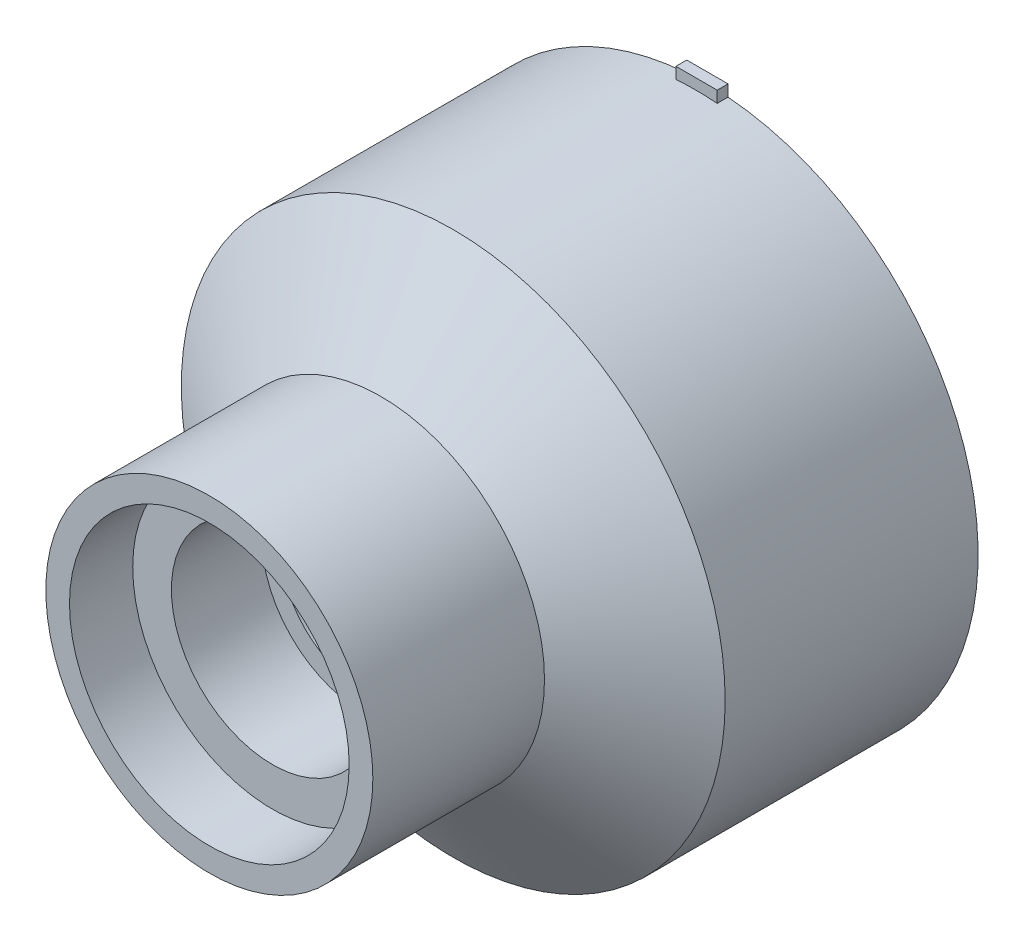
from build123d import *
from build123d.topology import SkipClean

# Parameters (mm, degrees)
CROQUIS1_R               = 15.05
CROQUIS1_R_2             = 14.05
SALIENTE_EXTRUIR1_DEPTH  = 0.6
SALIENTE_EXTRUIR2_DEPTH  = 0.4
CROQUIS5_R               = 15.05
CROQUIS5_R_2             = 14.05
SALIENTE_EXTRUIR3_DEPTH  = 0.4
CROQUIS7_R               = 15.05
CROQUIS7_R_2             = 14.05
SALIENTE_EXTRUIR4_DEPTH  = 13
CROQUIS8_W               = 2.286340663
CROQUIS8_H               = 1.122176033
SALIENTE_EXTRUIR5_DEPTH  = 0.6
CROQUIS10_R              = 6.525
CROQUIS10_R_2            = 4.525
SALIENTE_EXTRUIR6_DEPTH  = 1
CROQUIS11_R              = 9.05
CROQUIS11_R_2            = 5.6
SALIENTE_EXTRUIR7_DEPTH  = 5
CROQUIS12_R              = 9.05
CROQUIS12_R_2            = 8.05
SALIENTE_EXTRUIR9_DEPTH  = 1
CROQUIS13_R              = 9.05
CROQUIS13_R_2            = 7.74
SALIENTE_EXTRUIR10_DEPTH = 3.5
CROQUIS14_R              = 8.05
CROQUIS14_R_2            = 6.525
SALIENTE_EXTRUIR11_DEPTH = 1


with BuildPart() as part:
    # Croquis1 → Saliente-Extruir1 (new body)
    with BuildSketch(Plane.XY):
        Circle(CROQUIS1_R)
        Circle(CROQUIS1_R_2, mode=Mode.SUBTRACT)
    extrude(amount=SALIENTE_EXTRUIR1_DEPTH)

    # Croquis2 → Saliente-Extruir2 (add)
    with SkipClean():  # the faces are left unmerged after this step: merging them gives an invalid solid
        with BuildSketch(Plane(origin=(0, 0, 0), x_dir=(-1, 0, 0), z_dir=(0, 0, -1))):
            with BuildLine():
                Line((-2.404789938, 14.856631023), (-2.404789938, 13.842669011))
                ThreePointArc((-2.404789938, 13.842669011), (0, 14.05), (2.404789938, 13.842669011))
                Line((2.404789938, 13.842669011), (2.404789938, 14.856631023))
                ThreePointArc((2.404789938, 14.856631023), (0, 15.05), (-2.404789938, 14.856631023))
            make_face()
            with BuildLine():
                Line((14.856631023, 2.404789938), (13.842669011, 2.404789938))
                ThreePointArc((13.842669011, 2.404789938), (14.05, 0), (13.842669011, -2.404789938))
                Line((13.842669011, -2.404789938), (14.856631023, -2.404789938))
                ThreePointArc((14.856631023, -2.404789938), (15.05, 0), (14.856631023, 2.404789938))
            make_face()
            with BuildLine():
                Line((2.404789938, -14.856631023), (2.404789938, -13.842669011))
                ThreePointArc((2.404789938, -13.842669011), (0, -14.05), (-2.404789938, -13.842669011))
                Line((-2.404789938, -13.842669011), (-2.404789938, -14.856631023))
                ThreePointArc((-2.404789938, -14.856631023), (0, -15.05), (2.404789938, -14.856631023))
            make_face()
            with BuildLine():
                Line((-14.856631023, -2.404789938), (-13.842669011, -2.404789938))
                ThreePointArc((-13.842669011, -2.404789938), (-14.05, 0), (-13.842669011, 2.404789938))
                Line((-13.842669011, 2.404789938), (-14.856631023, 2.404789938))
                ThreePointArc((-14.856631023, 2.404789938), (-15.05, 0), (-14.856631023, -2.404789938))
            make_face()
        extrude(amount=SALIENTE_EXTRUIR2_DEPTH)

    # Croquis4 → Revolución1 (revolve)
    with SkipClean():  # the faces are left unmerged after this step: merging them gives an invalid solid
        with BuildSketch(Plane(origin=(0, 0, 0), x_dir=(0, 0, -1), z_dir=(1, 0, 0)), mode=Mode.PRIVATE) as revoluci_n1_sk:
            Polygon((-0.6, 15.05), (-4.6, 9.05), (-4.6, 8.05), (-0.6, 14.05), align=None)
        revolve(revoluci_n1_sk.sketch.rotate(Axis((0, 0, 0), (0, 0, 1)), 80.14476262), axis=Axis((0, 0, 0), (0, 0, 1)))

    # Croquis5 → Saliente-Extruir3 (add)
    with SkipClean():  # the faces are left unmerged after this step: merging them gives an invalid solid
        with BuildSketch(Plane(origin=(0, 0, 0), x_dir=(-1, 0, 0), z_dir=(0, 0, -1))):
            Circle(CROQUIS5_R)
            Circle(CROQUIS5_R_2, mode=Mode.SUBTRACT)
        extrude(amount=SALIENTE_EXTRUIR3_DEPTH)

    # Croquis7 → Saliente-Extruir4 (add)
    with SkipClean():  # the faces are left unmerged after this step: merging them gives an invalid solid
        with BuildSketch(Plane(origin=(0, 0, -0.4), x_dir=(-1, 0, 0), z_dir=(0, 0, -1))):
            Circle(CROQUIS7_R)
            Circle(CROQUIS7_R_2, mode=Mode.SUBTRACT)
        extrude(amount=SALIENTE_EXTRUIR4_DEPTH)

    # Croquis8 → Saliente-Extruir5 (add)
    with SkipClean():  # the faces are left unmerged after this step: merging them gives an invalid solid
        with BuildSketch(Plane(origin=(0, 0, -13.4), x_dir=(-1, 0, 0), z_dir=(0, 0, -1))):
            with Locations((-0.064707754, 15.075419169)):
                Rectangle(CROQUIS8_W, CROQUIS8_H)
        extrude(amount=-SALIENTE_EXTRUIR5_DEPTH)



with BuildPart() as body_2:
    # Croquis10 → Saliente-Extruir6 (new body)
    with BuildSketch(Plane.XY.offset(4.6)):
        Circle(CROQUIS10_R)
        Circle(CROQUIS10_R_2, mode=Mode.SUBTRACT)
    extrude(amount=SALIENTE_EXTRUIR6_DEPTH)

    # Croquis11 → Saliente-Extruir7 (add)
    with BuildSketch(Plane.XY.offset(5.6)):
        Circle(CROQUIS11_R)
        Circle(CROQUIS11_R_2, mode=Mode.SUBTRACT)
    extrude(amount=SALIENTE_EXTRUIR7_DEPTH)


with BuildPart() as part_1:
    with SkipClean():  # the faces are left unmerged after this step: merging them gives an invalid solid
        add(part.part)

        add(body_2.part)  # Saliente-Extruir9 merges body 2
        # Croquis12 → Saliente-Extruir9 (add)
        with BuildSketch(Plane.XY.offset(4.6)):
            Circle(CROQUIS12_R)
            with Locations(Location((0, 0, 0), (0, 0, 90))):
                Circle(CROQUIS12_R_2, mode=Mode.SUBTRACT)
        extrude(amount=SALIENTE_EXTRUIR9_DEPTH)

    # Croquis13 → Saliente-Extruir10 (add)
    with SkipClean():  # the faces are left unmerged after this step: merging them gives an invalid solid
        with BuildSketch(Plane.XY.offset(10.6)):
            Circle(CROQUIS13_R)
            Circle(CROQUIS13_R_2, mode=Mode.SUBTRACT)
        extrude(amount=SALIENTE_EXTRUIR10_DEPTH)

    # Croquis14 → Saliente-Extruir11 (add)
    with SkipClean():  # the faces are left unmerged after this step: merging them gives an invalid solid
        with BuildSketch(Plane(origin=(0, 0, 4.6), x_dir=(-1, 0, 0), z_dir=(0, 0, -1))):
            Circle(CROQUIS14_R)
            Circle(CROQUIS14_R_2, mode=Mode.SUBTRACT)
        extrude(amount=-SALIENTE_EXTRUIR11_DEPTH)


solid = part_1.part
